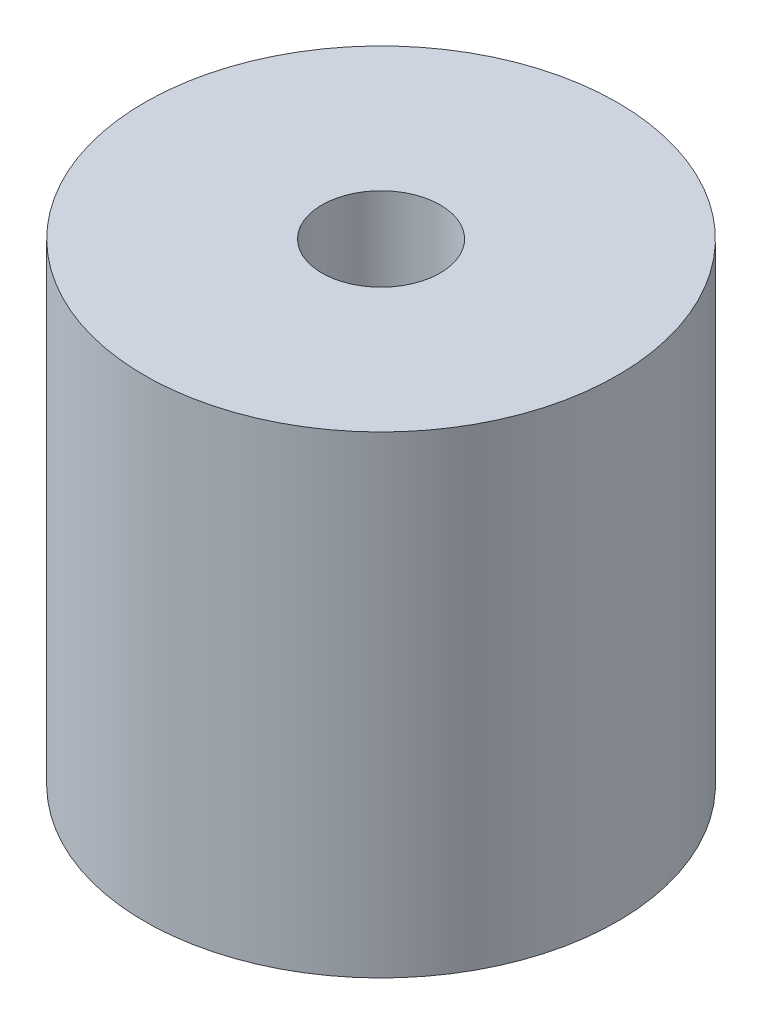
from build123d import *


with BuildPart() as part:
    # Sketch1 → Revolve1 (revolve)
    with BuildSketch(Plane.XY):
        Polygon((3, 0), (3, 10), (2.5, 10), (2.5, 20), (10, 20), (10, 0), align=None)
    revolve(axis=Axis((0, 0, 0), (0, 1, 0)))


solid = part.part
